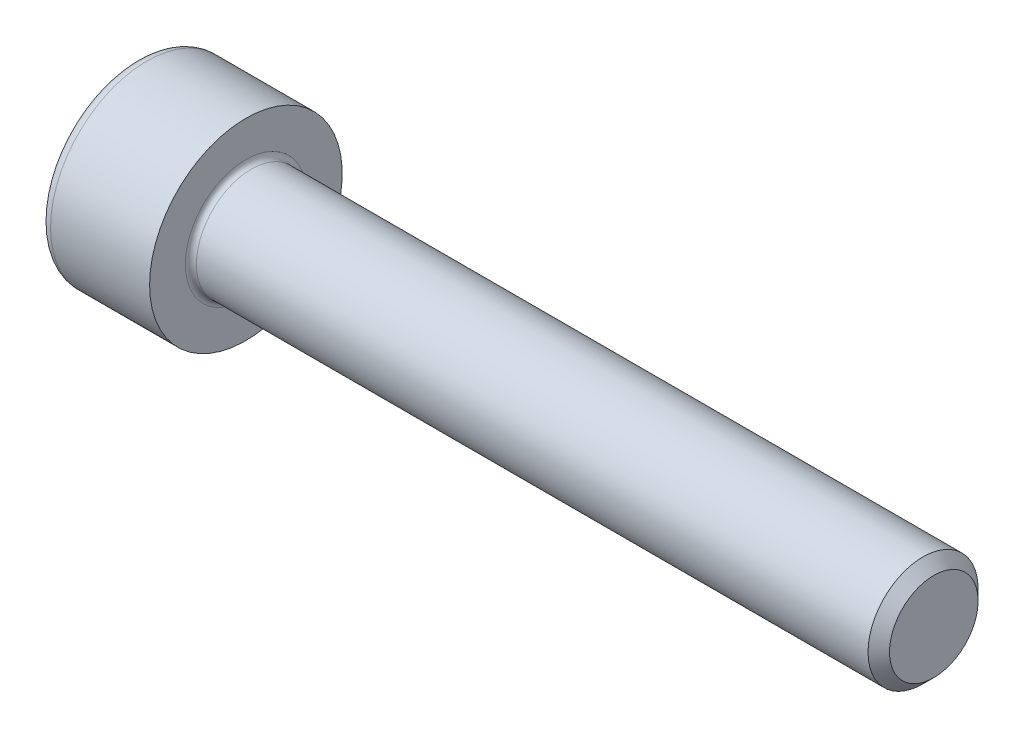
from build123d import *

# Parameters (mm, degrees)
FILLET1_R   = 0.2
FILLET2_R   = 0.4
HEX_2_DEPTH = 2


with BuildPart() as part:
    # BodySke → Base-Revolve (revolve)
    with BuildSketch(Plane.XY):
        Polygon((0, 0), (0, 3.5), (4, 3.5), (4, 2), (28.61, 2), (29, 1.61), (29, 0), align=None)
    revolve(axis=Axis((-31.75, 0, 0), (1, 0, 0)))

    # Fillet1
    fillet1_edges = [part.edges().sort_by_distance(p)[0] for p in [
        (4, -2, 0),
    ]]
    fillet(fillet1_edges, radius=FILLET1_R)

    # Fillet2
    fillet2_edges = [part.edges().sort_by_distance(p)[0] for p in [
        (0, -3.5, 0),
    ]]
    fillet(fillet2_edges, radius=FILLET2_R)

    # Sketch2 → Hex-PreBroach (revolve, cut)
    with BuildSketch(Plane.XY):
        Polygon((0, 1.51), (2, 1.51), (2.871798906, 0), (0, 0), align=None)
    revolve(axis=Axis((0, 0, 0), (1, 0, 0)), mode=Mode.SUBTRACT)

    # Sketch3 → Hex 2 (cut)
    with BuildSketch(Plane(origin=(0, 0, 0), x_dir=(0, 0.5, 0.866025404), z_dir=(-1, 0, 0))):
        Polygon((0.871798906, 1.51), (-0.871798906, 1.51), (-1.743597813, 0), (-0.871798906, -1.51), (0.871798906, -1.51), (1.743597813, 0), align=None)
    extrude(amount=-HEX_2_DEPTH, mode=Mode.SUBTRACT)


solid = part.part
